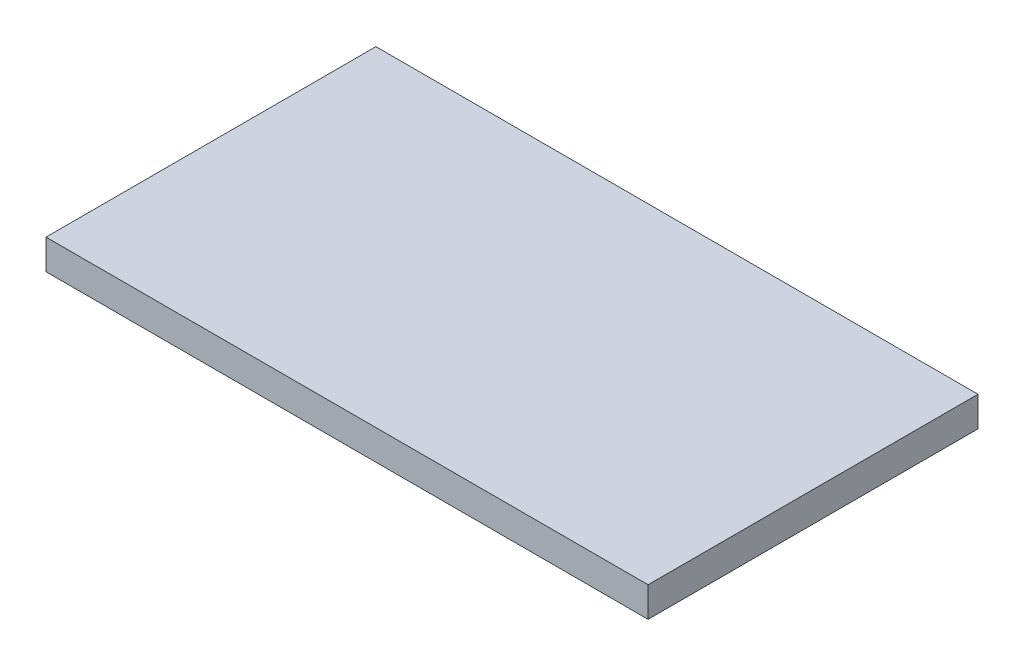
from build123d import *

# Parameters (mm, degrees)
SKETCH1_W           = 200.75
SKETCH1_H           = 110
BOSS_EXTRUDE1_DEPTH = 10


with BuildPart() as part:
    # Sketch1 → Boss-Extrude1 (new body)
    with BuildSketch(Plane(origin=(0, 0, 0), x_dir=(1, 0, 0), z_dir=(0, 1, 0))):
        with Locations((100.375, -55)):
            Rectangle(SKETCH1_W, SKETCH1_H)
    extrude(amount=BOSS_EXTRUDE1_DEPTH)


solid = part.part
